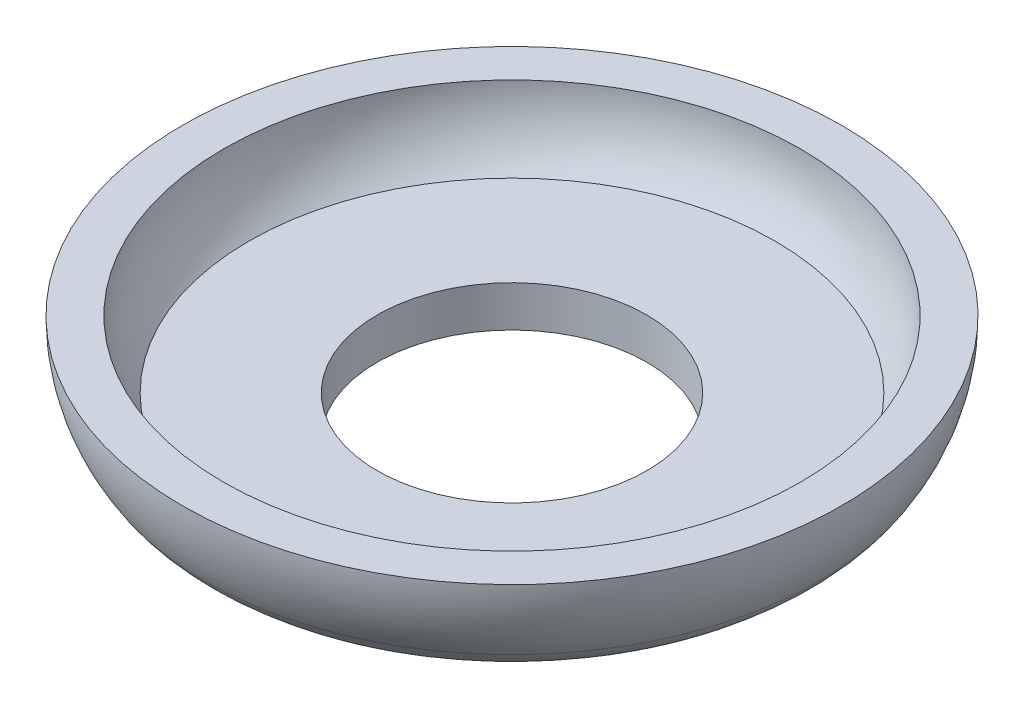
from build123d import *


with BuildPart() as part:
    # Sketch1 → Revolve1 (revolve)
    with BuildSketch(Plane.XY):
        with BuildLine():
            Line((5.0165, 0), (9.280631004, 0))
            ThreePointArc((9.280631004, 0), (10.494721496, 0.308949961), (11.413463004, 1.160642302))
            ThreePointArc((11.413463004, 1.160642302), (12.040594592, 2.526079315), (12.2555, 4.0132))
            Line((12.2555, 4.0132), (10.7315, 4.0132))
            ThreePointArc((10.7315, 4.0132), (10.485243398, 2.680592322), (9.779, 1.524))
            Line((9.779, 1.524), (5.0165, 1.524))
            Line((5.0165, 1.524), (5.0165, 0))
        make_face()
    revolve(axis=Axis((0, 0, 0), (0, 1, 0)))


solid = part.part
